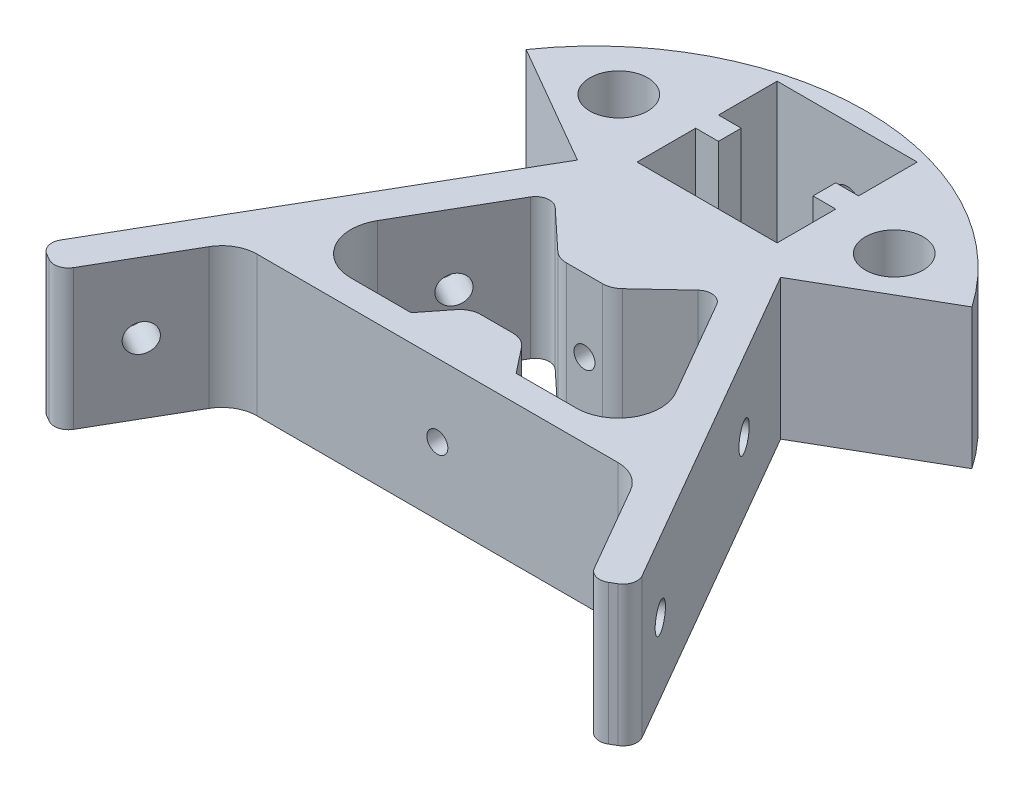
from build123d import *

# Parameters (mm, degrees)
SKETCH1_R                  = 4.125
BOSS_EXTRUDE1_DEPTH        = 20
FILLET2_R                  = 5
FILLET3_R                  = 5
FILLET4_R                  = 6
FILLET5_R                  = 6
FILLET6_R                  = 2
FILLET7_R                  = 3
FILLET10_R                 = 2
UPPER_VERTEX_HOLES_D       = 3
UPPER_VERTEX_HOLES_DEPTH   = 30
UPPER_VERTEX_HOLES_TIP     = 0.901290929
F_8_0_199_DIAMETER_HOLE2_D = 4
F_8_0_199_DIAMETER_HOLE3_D = 4
SKETCH12_W                 = 2
SKETCH12_H                 = 41.945563192
SKETCH16_W                 = 2
SKETCH16_H                 = 41.945563192


with BuildPart() as part:
    # Sketch1 → Boss-Extrude1 (new body)
    with BuildSketch(Plane(origin=(0, 0, 0), x_dir=(1, 0, 0), z_dir=(0, 1, 0))):
        with BuildLine():
            Line((-28.643593539, -10.537386441), (-38.169872981, -27.037386441))
            Line((-38.169872981, -27.037386441), (-42.5, -24.537386441))
            Line((-42.5, -24.537386441), (-14.5, 23.960036171))
            Line((-14.5, 23.960036171), (-31.820508076, 33.960036171))
            ThreePointArc((-31.820508076, 33.960036171), (0, 50.621689136), (31.820508076, 33.960036171))
            Line((31.820508076, 33.960036171), (14.5, 23.960036171))
            Line((14.5, 23.960036171), (42.5, -24.537386441))
            Line((42.5, -24.537386441), (38.169872981, -27.037386441))
            Line((38.169872981, -27.037386441), (28.643593539, -10.537386441))
            Line((28.643593539, -10.537386441), (-28.643593539, -10.537386441))
        make_face()
        with Locations((19.660254038, 35.022213998)):
            Circle(SKETCH1_R, mode=Mode.SUBTRACT)
        with Locations((-19.660254038, 35.022213998)):
            Circle(SKETCH1_R, mode=Mode.SUBTRACT)
        Polygon((-12.0447733, 18.212613559), (-26.47853003, -6.787386441), (-7.5, -6.787386441), (-3.75, -2.037386441), (3.75, -2.037386441), (7.5, -6.787386441), (26.47853003, -6.787386441), (12.0447733, 18.212613559), (3.75, 10.462613559), (-3.75, 10.462613559), align=None, mode=Mode.SUBTRACT)
        Polygon((-9.999491924, 47.962613559), (10.000508076, 47.962613559), (10.000508076, 39.587613559), (6.750508076, 39.587613559), (6.750508076, 36.337613559), (10.000508076, 36.337613559), (10.000508076, 27.962613559), (-9.999491924, 27.962613559), (-9.999491924, 36.337613559), (-6.749491924, 36.337613559), (-6.749491924, 39.587613559), (-9.999491924, 39.587613559), align=None, mode=Mode.SUBTRACT)
    extrude(amount=BOSS_EXTRUDE1_DEPTH)

    # Fillet2
    fillet2_edges = [part.edges().sort_by_distance(p)[0] for p in [
        (-28.643593539, 10, 10.537386441),
    ]]
    fillet(fillet2_edges, radius=FILLET2_R)

    # Fillet3
    fillet3_edges = [part.edges().sort_by_distance(p)[0] for p in [
        (28.643593539, 10, 10.537386441),
    ]]
    fillet(fillet3_edges, radius=FILLET3_R)

    # Fillet4
    fillet4_edges = [part.edges().sort_by_distance(p)[0] for p in [
        (-26.47853003, 10, 6.787386441),
    ]]
    fillet(fillet4_edges, radius=FILLET4_R)

    # Fillet5
    fillet5_edges = [part.edges().sort_by_distance(p)[0] for p in [
        (26.47853003, 10, 6.787386441),
    ]]
    fillet(fillet5_edges, radius=FILLET5_R)

    # Fillet6
    fillet6_edges = [part.edges().sort_by_distance(p)[0] for p in [
        (-12.0447733, 10, -18.212613559),
        (12.0447733, 10, -18.212613559),
    ]]
    fillet(fillet6_edges, radius=FILLET6_R)

    # Fillet7
    fillet7_edges = [part.edges().sort_by_distance(p)[0] for p in [
        (-3.75, 10, -10.462613559),
        (-3.75, 10, 2.037386441),
        (3.75, 10, 2.037386441),
        (3.75, 10, -10.462613559),
    ]]
    fillet(fillet7_edges, radius=FILLET7_R)

    # Fillet10
    fillet10_edges = [part.edges().sort_by_distance(p)[0] for p in [
        (-38.169872981, 10, 27.037386441),
        (-42.5, 10, 24.537386441),
        (42.5, 10, 24.537386441),
        (38.169872981, 10, 27.037386441),
    ]]
    fillet(fillet10_edges, radius=FILLET10_R)

    # Upper Vertex Holes
    with Locations(Plane.XY.offset(10.537386441)):
        with Locations((0, 9.632614612)):
            Hole(UPPER_VERTEX_HOLES_D / 2, depth=UPPER_VERTEX_HOLES_DEPTH)
            with Locations((0, 0, -(UPPER_VERTEX_HOLES_DEPTH + UPPER_VERTEX_HOLES_TIP / 2))):  # 118° drill point
                Cone(0, UPPER_VERTEX_HOLES_D / 2, UPPER_VERTEX_HOLES_TIP, mode=Mode.SUBTRACT)

    # #8 (0.199) Diameter Hole2 (through all)
    with Locations(Plane(origin=(16.919872981, 0, -9.76869322), x_dir=(0.5, 0, 0.866025404), z_dir=(-0.866025404, 0, 0.5))):
        with Locations((33.417096231, 10)):
            Hole(F_8_0_199_DIAMETER_HOLE2_D / 2)

    # #8 (0.199) Diameter Hole3 (through all)
    with Locations(Plane(origin=(-16.919872981, 0, -9.76869322), x_dir=(0.5, 0, -0.866025404), z_dir=(0.866025404, 0, 0.5))):
        with Locations((-33.417096231, 10)):
            Hole(F_8_0_199_DIAMETER_HOLE3_D / 2)

    # Sketch12 → #8 (0.199) Diameter Hole5 (revolve, cut)
    with BuildSketch(Plane(origin=(17.292785365, 10, -9.122790024), x_dir=(0.5, 0, 0.866025404), z_dir=(0, 1, 0))):
        with Locations((1, 20.972781596)):
            Rectangle(SKETCH12_W, SKETCH12_H)
    revolve(axis=Axis((11.793524051, 10, -5.947790024), (0.866025404, 0, -0.5)), mode=Mode.SUBTRACT)

    # Sketch16 → #8 (0.199) Diameter Hole6 (revolve, cut)
    with BuildSketch(Plane(origin=(-17.292785365, 10, -9.122790024), x_dir=(0.5, 0, -0.866025404), z_dir=(0, 1, 0))):
        with Locations((1, 20.972781596)):
            Rectangle(SKETCH16_W, SKETCH16_H)
    revolve(axis=Axis((-11.793524051, 10, -5.947790024), (-0.866025404, 0, -0.5)), mode=Mode.SUBTRACT)

    # Sketch18 → #8 (0.199) Diameter Hole7 (revolve, cut)
    with BuildSketch(Plane(origin=(0.000508076, 10, -47.962613559), x_dir=(0, -1, 0), z_dir=(1, 0, 0))):
        Polygon((0, 0), (0, 31.2017212), (1.999999937, 30), (1.999999937, 0), align=None)
    revolve(axis=Axis((0.000508076, 10, -41.612613559), (0, 0, -1)), mode=Mode.SUBTRACT)


solid = part.part
